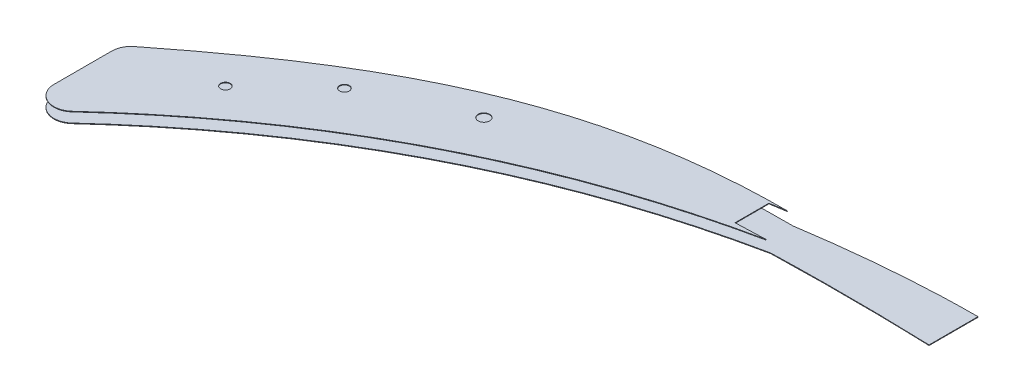
from build123d import *

# Parameters (mm, degrees)
DODANIE_WYCI_GNI_CIE1_DEPTH = 0.3
DODANIE_WYCI_GNI_CIE2_DEPTH = 0.3
SZKIC3_R                    = 2.5
SZKIC3_R_2                  = 3
WYTNIJ_WYCI_GNI_CIE1_DEPTH  = 12


with BuildPart() as part:
    # Szkic1 → Dodanie-wyciągnięcie1 (new body)
    with BuildSketch(Plane.XZ.offset(-295)):
        with BuildLine():
            Line((-77.187477809, 238.371526152), (-77.187477809, 263.787467627))
            add(Edge.make_bspline(
                [(-77.187477809, 263.787467627), (-90.931891454, 263.302665158), (-104.681952299, 263.050489589), (-132.179761623, 262.98712509), (-145.931371492, 263.172070993), (-159.678350984, 263.562143643)],
                knots=[0, 0, 0, 0, 0.5, 0.5, 1, 1, 1, 1], degree=3))
            add(Edge.make_bspline(
                [(-159.678350984, 263.562143643), (-250.706696635, 282.330267514), (-331.16632582, 323.598422626), (-399.451682504, 386.496425626)],
                knots=[0, 0, 0, 0, 0.864061194, 0.864061194, 0.864061194, 0.864061194], degree=3))
            ThreePointArc((-399.451682504, 386.496425626), (-410.242264679, 388.299488123), (-416.226649581, 379.141167568))
            Line((-416.226649581, 379.141167568), (-416.226649581, 349.123356926))
            ThreePointArc((-416.226649581, 349.123356926), (-415.225213611, 344.76149432), (-412.421480502, 341.273256936))
            add(Edge.make_bspline(
                [(-412.421480502, 341.273256936), (-337.562441747, 282.198966343), (-268.684783511, 244.73497802), (-166.046176885, 245.61070335)],
                knots=[0.076862335, 0.076862335, 0.076862335, 0.076862335, 0.98459041, 0.98459041, 0.98459041, 0.98459041], degree=3))
            add(Edge.make_bspline(
                [(-166.046176885, 245.61070335), (-158.691588186, 244.479612696), (-151.319796636, 243.468209688), (-136.557675168, 241.699121012), (-129.165088755, 240.940959885), (-114.354878372, 239.699183419), (-106.937301858, 239.215047722), (-95.790102143, 238.717306802), (-92.070055878, 238.589825858), (-84.62985785, 238.417469406), (-80.909047989, 238.372473536), (-77.187477809, 238.371526152)],
                knots=[0, 0, 0, 0, 0.25, 0.25, 0.5, 0.5, 0.75, 0.75, 0.875, 0.875, 1, 1, 1, 1], degree=3))
        make_face()
    extrude(amount=DODANIE_WYCI_GNI_CIE1_DEPTH)


with BuildPart() as body_2:
    # Szkic2 → Dodanie-wyciągnięcie2 (new body)
    with BuildSketch(Plane(origin=(0, 300, 0), x_dir=(1, 0, 0), z_dir=(0, 1, 0))):
        with BuildLine():
            Line((-177.187477809, -264.509119585), (-177.187477809, -246.945846168))
            ThreePointArc((-177.187477809, -246.945846168), (-172.97904925, -246.258320434), (-168.766510621, -245.596443654))
            add(Edge.make_bspline(
                [(-168.766510621, -245.596443654), (-269.905820359, -245.400566453), (-338.225722809, -282.722388215), (-412.421480502, -341.273256936)],
                knots=[0.084905169, 0.084905169, 0.084905169, 0.084905169, 0.98459041, 0.98459041, 0.98459041, 0.98459041], degree=3))
            ThreePointArc((-412.421480502, -341.273256936), (-415.225213611, -344.76149432), (-416.226649581, -349.123356926))
            Line((-416.226649581, -349.123356926), (-416.226649581, -379.141167568))
            ThreePointArc((-416.226649581, -379.141167568), (-410.242264679, -388.299488123), (-399.451682504, -386.496425626))
            add(Edge.make_bspline(
                [(-399.451682504, -386.496425626), (-331.649658003, -324.043622455), (-251.84509308, -282.915553357), (-161.609691541, -263.964054369)],
                knots=[0, 0, 0, 0, 0.857945262, 0.857945262, 0.857945262, 0.857945262], degree=3))
            add(Edge.make_bspline(
                [(-161.609691541, -263.964054369), (-163.461784936, -264.018551283), (-167.684740985, -264.151245151), (-172.876910079, -264.337762118), (-176.217014145, -264.469751133), (-177.187477809, -264.509119585)],
                knots=[0.455950291, 0.455950291, 0.455950291, 0.455950291, 0.480354949, 0.511604949, 0.524404658, 0.524404658, 0.524404658, 0.524404658], degree=3))
        make_face()
    extrude(amount=DODANIE_WYCI_GNI_CIE2_DEPTH)


with BuildPart() as wytnij_wyci_gni_cie1_tool:
    # Szkic3 → Wytnij-wyciągnięcie1 (new body)
    with BuildSketch(Plane(origin=(0, 300.3, 0), x_dir=(1, 0, 0), z_dir=(0, 1, 0))):
        with Locations((-370.956911026, -335.367132453)):
            Circle(SZKIC3_R)
        with Locations((-339.082998521, -305.429754445)):
            Circle(SZKIC3_R)
        with Locations((-289.68705591, -282.424125213)):
            Circle(SZKIC3_R_2)
    extrude(amount=-WYTNIJ_WYCI_GNI_CIE1_DEPTH)


with BuildPart() as part_1:
    add(part.part)

    # Wytnij-wyciągnięcie1: cut by wytnij_wyci_gni_cie1_tool
    add(wytnij_wyci_gni_cie1_tool.part, mode=Mode.SUBTRACT)


with BuildPart() as body_2_1:
    add(body_2.part)

    # Wytnij-wyciągnięcie1: cut by wytnij_wyci_gni_cie1_tool
    add(wytnij_wyci_gni_cie1_tool.part, mode=Mode.SUBTRACT)


solid = Compound([part_1.part, body_2_1.part])
